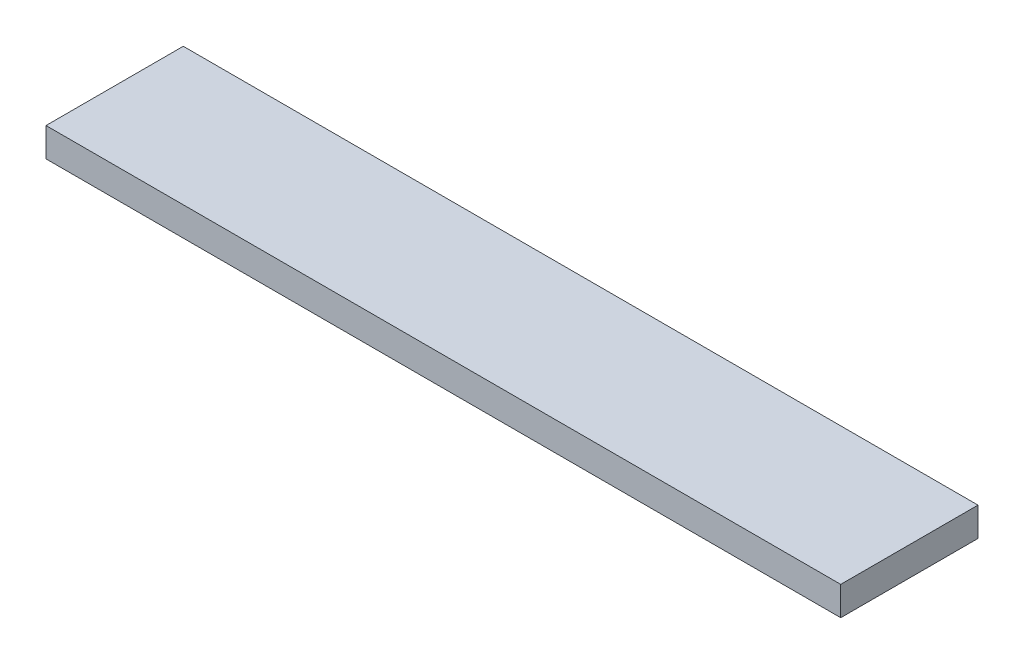
from build123d import *

# Parameters (mm, degrees)
SKETCH1_W           = 69.85
SKETCH1_H           = 12.065
BOSS_EXTRUDE1_DEPTH = 2.54


with BuildPart() as part:
    # Sketch1 → Boss-Extrude1 (new body)
    with BuildSketch(Plane(origin=(0, 0, 0), x_dir=(1, 0, 0), z_dir=(0, 1, 0))):
        with Locations((34.925, 6.0325)):
            Rectangle(SKETCH1_W, SKETCH1_H)
    extrude(amount=BOSS_EXTRUDE1_DEPTH)


solid = part.part
